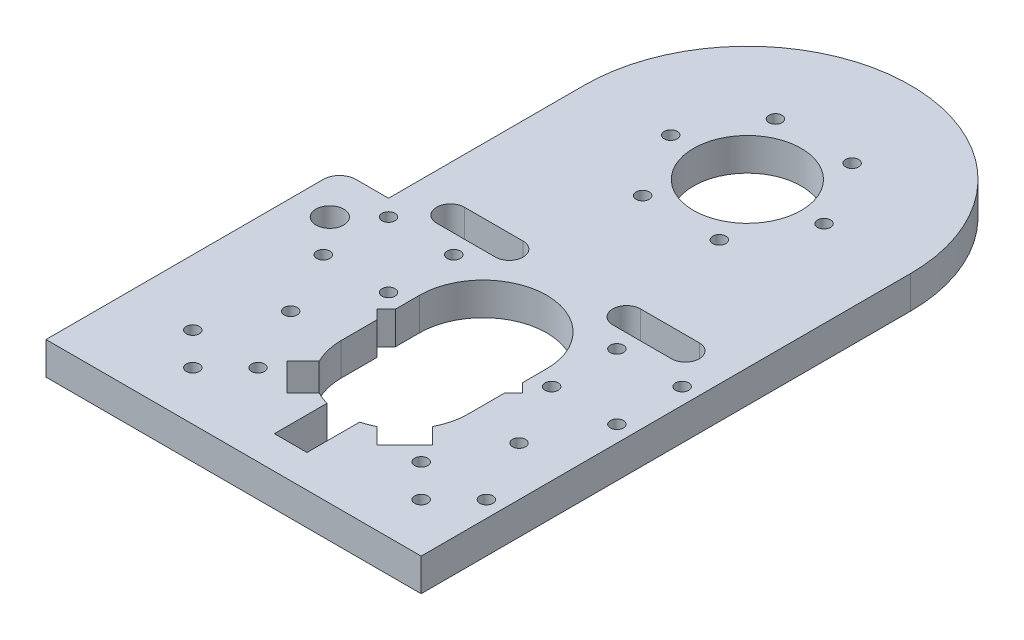
from build123d import *

# Parameters (mm, degrees)
SKETCH1_R           = 16.5
SKETCH1_R_2         = 2
BOSS_EXTRUDE3_DEPTH = 10
SKETCH2_R           = 19.5
CUT_EXTRUDE1_DEPTH  = 10
CUT_EXTRUDE2_DEPTH  = 10
CUT_EXTRUDE3_DEPTH  = 10
CUT_EXTRUDE6_DEPTH  = 10
SKETCH9_W           = 90
SKETCH9_H           = 10
BOSS_EXTRUDE4_DEPTH = 15
FILLET1_R           = 5
SKETCH10_R          = 4.25
CUT_EXTRUDE7_DEPTH  = 10
CUT_EXTRUDE8_DEPTH  = 10


with BuildPart() as part:
    # Sketch1 → Boss-Extrude3 (new body)
    with BuildSketch(Plane(origin=(0, 0, 0), x_dir=(1, 0, 0), z_dir=(0, 1, 0))):
        with BuildLine():
            Line((-52.326392464, -141.880675109), (47.673607536, -141.880675109))
            Line((47.673607536, -141.880675109), (47.673607536, 8.119324891))
            ThreePointArc((47.673607536, 8.119324891), (-2.326392464, 58.119324891), (-52.326392464, 8.119324891))
            Line((-52.326392464, 8.119324891), (-52.326392464, -141.880675109))
        make_face()
        with Locations((-2.326392464, 8.119324891)):
            Circle(SKETCH1_R, mode=Mode.SUBTRACT)
        with Locations((21.173607536, 8.119324891)):
            Circle(SKETCH1_R_2, mode=Mode.SUBTRACT)
        with Locations((9.423607536, -12.232272098)):
            Circle(SKETCH1_R_2, mode=Mode.SUBTRACT)
        with Locations((-14.076392464, -12.232272098)):
            Circle(SKETCH1_R_2, mode=Mode.SUBTRACT)
        with Locations((-25.826392464, 8.119324891)):
            Circle(SKETCH1_R_2, mode=Mode.SUBTRACT)
        with Locations((-14.076392464, 28.47092188)):
            Circle(SKETCH1_R_2, mode=Mode.SUBTRACT)
        with Locations((9.423607536, 28.47092188)):
            Circle(SKETCH1_R_2, mode=Mode.SUBTRACT)
        with Locations((-47.326392464, -116.880675109)):
            Circle(SKETCH1_R_2, mode=Mode.SUBTRACT)
        with Locations((42.673607536, -116.880675109)):
            Circle(SKETCH1_R_2, mode=Mode.SUBTRACT)
        with Locations((-37.326392464, -126.880675109)):
            Circle(SKETCH1_R_2, mode=Mode.SUBTRACT)
        with Locations((-37.326392464, -96.880675109)):
            Circle(SKETCH1_R_2, mode=Mode.SUBTRACT)
        with Locations((-47.326392464, -76.880675109)):
            Circle(SKETCH1_R_2, mode=Mode.SUBTRACT)
        with Locations((42.673607536, -76.880675109)):
            Circle(SKETCH1_R_2, mode=Mode.SUBTRACT)
        with Locations((-47.326392464, -56.880675109)):
            Circle(SKETCH1_R_2, mode=Mode.SUBTRACT)
        with Locations((42.673607536, -56.880675109)):
            Circle(SKETCH1_R_2, mode=Mode.SUBTRACT)
        with Locations((-27.326392464, -116.880675109)):
            Circle(SKETCH1_R_2, mode=Mode.SUBTRACT)
        with Locations((22.673607536, -116.880675109)):
            Circle(SKETCH1_R_2, mode=Mode.SUBTRACT)
        with Locations((-27.326392464, -56.880675109)):
            Circle(SKETCH1_R_2, mode=Mode.SUBTRACT)
        with Locations((-27.326392464, -76.880675109)):
            Circle(SKETCH1_R_2, mode=Mode.SUBTRACT)
        with Locations((22.673607536, -56.880675109)):
            Circle(SKETCH1_R_2, mode=Mode.SUBTRACT)
        with Locations((22.673607536, -76.880675109)):
            Circle(SKETCH1_R_2, mode=Mode.SUBTRACT)
        with Locations((32.673607536, -96.880675109)):
            Circle(SKETCH1_R_2, mode=Mode.SUBTRACT)
        with Locations((32.673607536, -126.880675109)):
            Circle(SKETCH1_R_2, mode=Mode.SUBTRACT)
    extrude(amount=BOSS_EXTRUDE3_DEPTH)

    # Sketch2 → Cut-Extrude1 (cut)
    with BuildSketch(Plane(origin=(0, 10, 0), x_dir=(1, 0, 0), z_dir=(0, 1, 0))):
        with Locations((-2.326392464, -96.880675109)):
            Circle(SKETCH2_R)
    extrude(amount=-CUT_EXTRUDE1_DEPTH, mode=Mode.SUBTRACT)

    # Sketch3 → Cut-Extrude2 (cut)
    with BuildSketch(Plane(origin=(0, 10, 0), x_dir=(1, 0, 0), z_dir=(0, 1, 0))):
        with BuildLine():
            Line((-7.326392464, -131.880675109), (-7.326392464, -115.728751934))
            ThreePointArc((-7.326392464, -115.728751934), (-2.326392464, -116.380675109), (2.673607536, -115.728751934))
            Line((2.673607536, -115.728751934), (2.673607536, -131.880675109))
            Line((2.673607536, -131.880675109), (-7.326392464, -131.880675109))
        make_face()
    extrude(amount=-CUT_EXTRUDE2_DEPTH, mode=Mode.SUBTRACT)

    # Sketch4 → Cut-Extrude3 (cut)
    with BuildSketch(Plane(origin=(0, 10, 0), x_dir=(1, 0, 0), z_dir=(0, 1, 0))):
        with BuildLine():
            ThreePointArc((-19.688674915, -88.003674033), (-16.114974697, -83.092092876), (-11.203393541, -79.518392659))
            Line((-11.203393541, -79.518392659), (-16.114974697, -74.606811502))
            Line((-16.114974697, -74.606811502), (-24.600256072, -83.092092876))
            Line((-24.600256072, -83.092092876), (-19.688674915, -88.003674033))
        make_face()
        with BuildLine():
            Line((11.462189769, -74.606811502), (6.550608612, -79.518392659))
            ThreePointArc((6.550608612, -79.518392659), (11.462189769, -83.092092876), (15.035889986, -88.003674033))
            Line((15.035889986, -88.003674033), (19.947471143, -83.092092876))
            Line((19.947471143, -83.092092876), (11.462189769, -74.606811502))
        make_face()
        with BuildLine():
            Line((19.947471143, -110.669257342), (15.035889986, -105.757676186))
            ThreePointArc((15.035889986, -105.757676186), (11.462189769, -110.669257342), (6.550608612, -114.24295756))
            Line((6.550608612, -114.24295756), (11.462189769, -119.154538717))
            Line((11.462189769, -119.154538717), (19.947471143, -110.669257342))
        make_face()
        with BuildLine():
            ThreePointArc((-11.203393541, -114.24295756), (-16.114974697, -110.669257342), (-19.688674915, -105.757676186))
            Line((-19.688674915, -105.757676186), (-24.600256072, -110.669257342))
            Line((-24.600256072, -110.669257342), (-16.114974697, -119.154538717))
            Line((-16.114974697, -119.154538717), (-11.203393541, -114.24295756))
        make_face()
    extrude(amount=-CUT_EXTRUDE3_DEPTH, mode=Mode.SUBTRACT)

    # Sketch8 → Cut-Extrude6 (cut)
    with BuildSketch(Plane(origin=(0, 10, 0), x_dir=(1, 0, 0), z_dir=(0, 1, 0))):
        with BuildLine():
            Line((-21.826392464, -96.880675109), (17.173607536, -96.880675109))
            Line((17.173607536, -96.880675109), (17.173607536, -72.880675109))
            ThreePointArc((17.173607536, -72.880675109), (-2.326392464, -53.380675109), (-21.826392464, -72.880675109))
            Line((-21.826392464, -72.880675109), (-21.826392464, -96.880675109))
        make_face()
    extrude(amount=-CUT_EXTRUDE6_DEPTH, mode=Mode.SUBTRACT)

    # Sketch9 → Boss-Extrude4 (add)
    with BuildSketch(Plane.ZY.offset(52.326392464)):
        with Locations((96.880675109, 5)):
            Rectangle(SKETCH9_W, SKETCH9_H)
    extrude(amount=BOSS_EXTRUDE4_DEPTH)

    # Fillet1
    fillet1_edges = [part.edges().sort_by_distance(p)[0] for p in [
        (-67.326392464, 5, 51.880675109),
    ]]
    fillet(fillet1_edges, radius=FILLET1_R)

    # Sketch10 → Cut-Extrude7 (cut)
    with BuildSketch(Plane(origin=(0, 10, 0), x_dir=(1, 0, 0), z_dir=(0, 1, 0))):
        with Locations((-56.326392464, -65.880675109)):
            Circle(SKETCH10_R)
    extrude(amount=-CUT_EXTRUDE7_DEPTH, mode=Mode.SUBTRACT)

    # Sketch11 → Cut-Extrude8 (cut)
    with BuildSketch(Plane(origin=(0, 10, 0), x_dir=(1, 0, 0), z_dir=(0, 1, 0))):
        with BuildLine():
            Line((15.673607536, -42.630675109), (33.673607536, -42.630675109))
            ThreePointArc((33.673607536, -42.630675109), (37.923607536, -46.880675109), (33.673607536, -51.130675109))
            Line((33.673607536, -51.130675109), (15.673607536, -51.130675109))
            ThreePointArc((15.673607536, -51.130675109), (11.423607536, -46.880675109), (15.673607536, -42.630675109))
        make_face()
        with BuildLine():
            Line((-38.326392464, -42.630675109), (-20.326392464, -42.630675109))
            ThreePointArc((-20.326392464, -42.630675109), (-16.076392464, -46.880675109), (-20.326392464, -51.130675109))
            Line((-20.326392464, -51.130675109), (-38.326392464, -51.130675109))
            ThreePointArc((-38.326392464, -51.130675109), (-42.576392464, -46.880675109), (-38.326392464, -42.630675109))
        make_face()
    extrude(amount=-CUT_EXTRUDE8_DEPTH, mode=Mode.SUBTRACT)


solid = part.part
